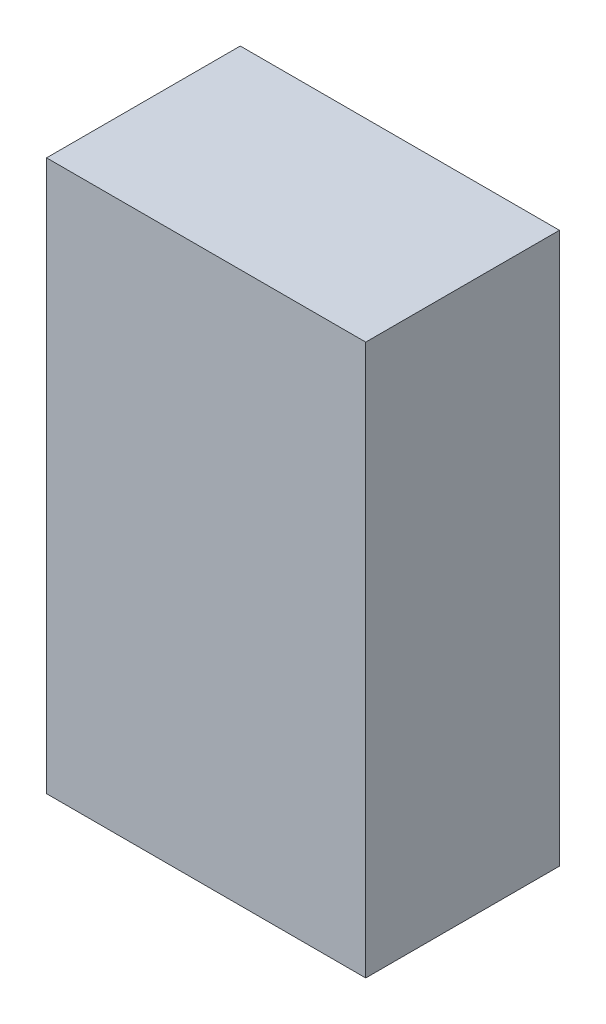
from build123d import *

# Parameters (mm, degrees)
SKETCH1_W           = 73.602498049
SKETCH1_H           = 44.669102263
BOSS_EXTRUDE1_DEPTH = 127


with BuildPart() as part:
    # Sketch1 → Boss-Extrude1 (new body)
    with BuildSketch(Plane(origin=(0, 0, 0), x_dir=(1, 0, 0), z_dir=(0, 1, 0))):
        with Locations((-2.791818892, 6.218142076)):
            Rectangle(SKETCH1_W, SKETCH1_H)
    extrude(amount=BOSS_EXTRUDE1_DEPTH)


solid = part.part
